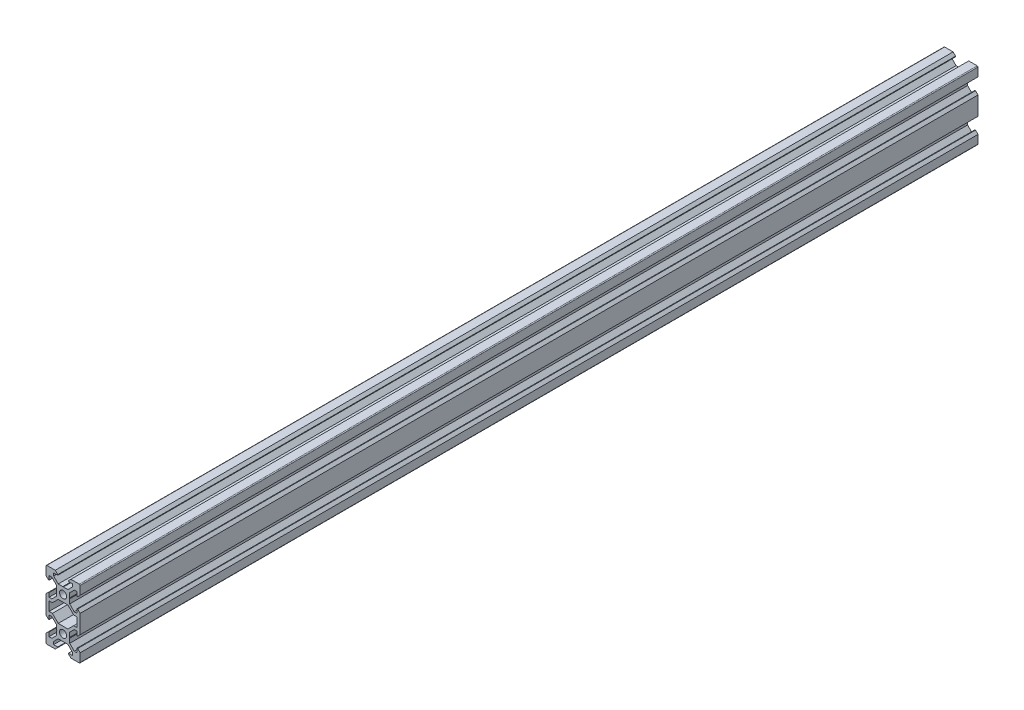
from build123d import *

# Parameters (mm, degrees)
SKETCH1_R           = 2.1
BOSS_EXTRUDE1_DEPTH = 526


with BuildPart() as part:
    # Sketch1 → Boss-Extrude1 (new body)
    with BuildSketch(Plane.XY):
        with BuildLine():
            Line((4.58, -20), (9.5, -20))
            ThreePointArc((9.5, -20), (9.853553391, -19.853553391), (10, -19.5))
            Line((10, -19.5), (10, -14.58))
            Line((10, -14.58), (8.545, -13.125))
            Line((8.545, -13.125), (8.2, -13.125))
            Line((8.2, -13.125), (8.2, -15.5))
            Line((8.2, -15.5), (6.560660172, -15.5))
            Line((6.560660172, -15.5), (3.9, -12.839339828))
            Line((3.9, -12.839339828), (3.9, -10.21))
            Line((3.9, -10.21), (3.69, -10))
            Line((3.69, -10), (3.9, -9.79))
            Line((3.9, -9.79), (3.9, -7.160660172))
            Line((3.9, -7.160660172), (6.560660172, -4.5))
            Line((6.560660172, -4.5), (8.2, -4.5))
            Line((8.2, -4.5), (8.2, -6.875))
            Line((8.2, -6.875), (8.545, -6.875))
            Line((8.545, -6.875), (10, -5.42))
            Line((10, -5.42), (10, 5.42))
            Line((10, 5.42), (8.545, 6.875))
            Line((8.545, 6.875), (8.2, 6.875))
            Line((8.2, 6.875), (8.2, 4.5))
            Line((8.2, 4.5), (6.560660172, 4.5))
            Line((6.560660172, 4.5), (3.9, 7.160660172))
            Line((3.9, 7.160660172), (3.9, 9.79))
            Line((3.9, 9.79), (3.69, 10))
            Line((3.69, 10), (3.9, 10.21))
            Line((3.9, 10.21), (3.9, 12.839339828))
            Line((3.9, 12.839339828), (6.560660172, 15.5))
            Line((6.560660172, 15.5), (8.2, 15.5))
            Line((8.2, 15.5), (8.2, 13.125))
            Line((8.2, 13.125), (8.545, 13.125))
            Line((8.545, 13.125), (10, 14.58))
            Line((10, 14.58), (10, 19.5))
            ThreePointArc((10, 19.5), (9.853553391, 19.853553391), (9.5, 20))
            Line((9.5, 20), (4.58, 20))
            Line((4.58, 20), (3.125, 18.545))
            Line((3.125, 18.545), (3.125, 18.2))
            Line((3.125, 18.2), (5.5, 18.2))
            Line((5.5, 18.2), (5.5, 16.560660172))
            Line((5.5, 16.560660172), (2.839339828, 13.9))
            Line((2.839339828, 13.9), (0.21, 13.9))
            Line((0.21, 13.9), (0, 13.69))
            Line((0, 13.69), (-0.21, 13.9))
            Line((-0.21, 13.9), (-2.839339828, 13.9))
            Line((-2.839339828, 13.9), (-5.5, 16.560660172))
            Line((-5.5, 16.560660172), (-5.5, 18.2))
            Line((-5.5, 18.2), (-3.125, 18.2))
            Line((-3.125, 18.2), (-3.125, 18.545))
            Line((-3.125, 18.545), (-4.58, 20))
            Line((-4.58, 20), (-9.5, 20))
            ThreePointArc((-9.5, 20), (-9.853553391, 19.853553391), (-10, 19.5))
            Line((-10, 19.5), (-10, 14.58))
            Line((-10, 14.58), (-8.545, 13.125))
            Line((-8.545, 13.125), (-8.2, 13.125))
            Line((-8.2, 13.125), (-8.2, 15.5))
            Line((-8.2, 15.5), (-6.560660172, 15.5))
            Line((-6.560660172, 15.5), (-3.9, 12.839339828))
            Line((-3.9, 12.839339828), (-3.9, 10.21))
            Line((-3.9, 10.21), (-3.69, 10))
            Line((-3.69, 10), (-3.9, 9.79))
            Line((-3.9, 9.79), (-3.9, 7.160660172))
            Line((-3.9, 7.160660172), (-6.560660172, 4.5))
            Line((-6.560660172, 4.5), (-8.2, 4.5))
            Line((-8.2, 4.5), (-8.2, 6.875))
            Line((-8.2, 6.875), (-8.545, 6.875))
            Line((-8.545, 6.875), (-10, 5.42))
            Line((-10, 5.42), (-10, -5.42))
            Line((-10, -5.42), (-8.545, -6.875))
            Line((-8.545, -6.875), (-8.2, -6.875))
            Line((-8.2, -6.875), (-8.2, -4.5))
            Line((-8.2, -4.5), (-6.560660172, -4.5))
            Line((-6.560660172, -4.5), (-3.9, -7.160660172))
            Line((-3.9, -7.160660172), (-3.9, -9.79))
            Line((-3.9, -9.79), (-3.69, -10))
            Line((-3.69, -10), (-3.9, -10.21))
            Line((-3.9, -10.21), (-3.9, -12.839339828))
            Line((-3.9, -12.839339828), (-6.560660172, -15.5))
            Line((-6.560660172, -15.5), (-8.2, -15.5))
            Line((-8.2, -15.5), (-8.2, -13.125))
            Line((-8.2, -13.125), (-8.545, -13.125))
            Line((-8.545, -13.125), (-10, -14.58))
            Line((-10, -14.58), (-10, -19.5))
            ThreePointArc((-10, -19.5), (-9.853553391, -19.853553391), (-9.5, -20))
            Line((-9.5, -20), (-4.58, -20))
            Line((-4.58, -20), (-3.125, -18.545))
            Line((-3.125, -18.545), (-3.125, -18.2))
            Line((-3.125, -18.2), (-5.5, -18.2))
            Line((-5.5, -18.2), (-5.5, -16.560660172))
            Line((-5.5, -16.560660172), (-2.839339828, -13.9))
            Line((-2.839339828, -13.9), (-0.21, -13.9))
            Line((-0.21, -13.9), (0, -13.69))
            Line((0, -13.69), (0.21, -13.9))
            Line((0.21, -13.9), (2.839339828, -13.9))
            Line((2.839339828, -13.9), (5.5, -16.560660172))
            Line((5.5, -16.560660172), (5.5, -18.2))
            Line((5.5, -18.2), (3.125, -18.2))
            Line((3.125, -18.2), (3.125, -18.545))
            Line((3.125, -18.545), (4.58, -20))
        make_face()
        with Locations((0, -10)):
            Circle(SKETCH1_R, mode=Mode.SUBTRACT)
        Polygon((-6.239339828, -2.7), (-8.2, -2.7), (-8.2, 2.7), (-6.239339828, 2.7), (-2.839339828, 6.1), (2.839339828, 6.1), (6.239339828, 2.7), (8.2, 2.7), (8.2, -2.7), (6.239339828, -2.7), (2.839339828, -6.1), (-2.839339828, -6.1), align=None, mode=Mode.SUBTRACT)
        with Locations((0, 10)):
            Circle(SKETCH1_R, mode=Mode.SUBTRACT)
    extrude(amount=BOSS_EXTRUDE1_DEPTH)


solid = part.part
